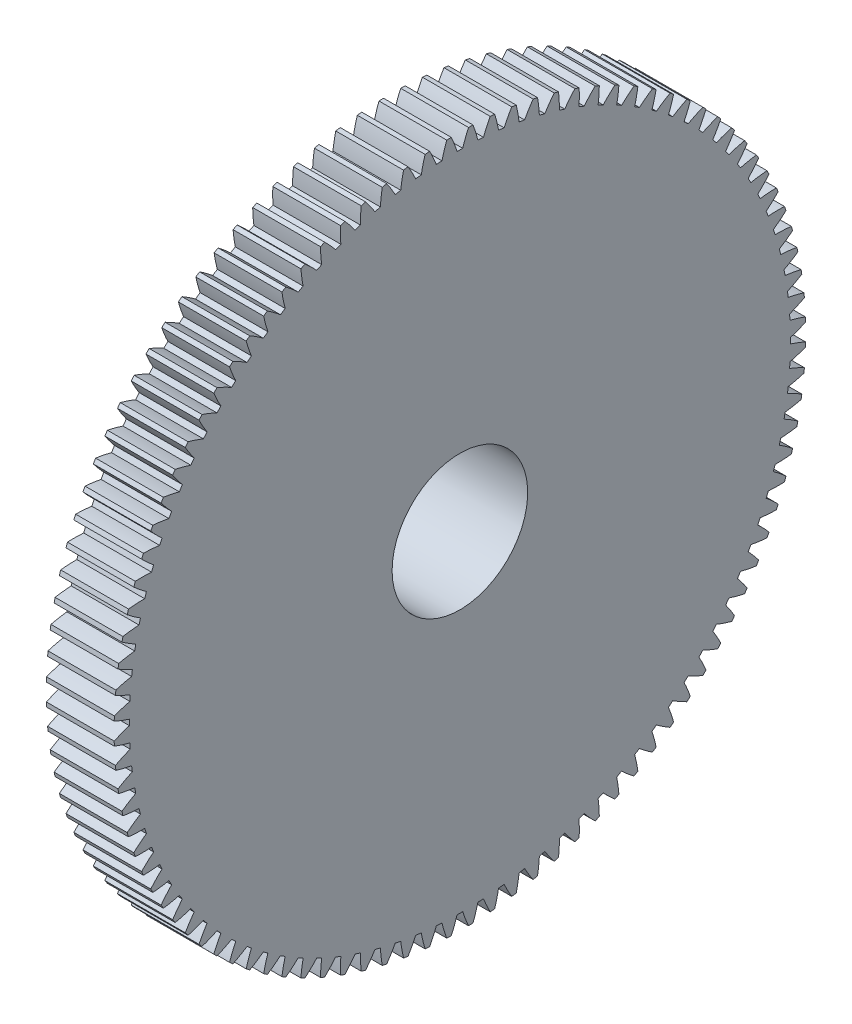
from build123d import *

# Parameters (mm, degrees)
BASPROSKE_W         = 10
BASPROSKE_H         = 51
TOOTHCUT_DEPTH      = 73.814833654
TEETHCUTS_COUNT     = 100
TEETHCUTS_ANGLE     = 356.4
HUBNEAONESKE_R      = 15
HUBNEARONE_DEPTH    = 12.7000508
BORSKE_R            = 10
BORE_DEPTH          = 10.0000508
SKETCH_1_R          = 39.02724458
CUT_EXTRUDE_1_DEPTH = 10


with BuildPart() as part:
    # BasProSke → Base-Revolve (revolve)
    with BuildSketch(Plane(origin=(0, 0, 0), x_dir=(1, 0, 0), z_dir=(0, 1, 0)), mode=Mode.PRIVATE) as base_revolve_sk:
        with Locations((5, 25.5)):
            Rectangle(BASPROSKE_W, BASPROSKE_H)
    revolve(base_revolve_sk.sketch.rotate(Axis((-10, 0, 0), (1, 0, 0)), 180), axis=Axis((-10, 0, 0), (1, 0, 0)))

    # TooCutSke → ToothCut (cut, through all)
    with BuildSketch(Plane(origin=(0, 0, 0), x_dir=(0, 0, -1), z_dir=(1, 0, 0))):
        with BuildLine():
            ThreePointArc((0.414680742, 48.747236238), (0, 48.749), (-0.414680742, 48.747236238))
            ThreePointArc((-0.414680742, 48.747236238), (-0.812805308, 49.891397747), (-1.279472386, 51.009355961))
            ThreePointArc((-1.279472386, 51.009355961), (0, 51.0254), (1.279472386, 51.009355961))
            ThreePointArc((1.279472386, 51.009355961), (0.812805308, 49.891397747), (0.414680742, 48.747236238))
        make_face()
    toothcut = extrude(amount=TOOTHCUT_DEPTH, mode=Mode.SUBTRACT)

    # TeethCuts: ToothCut ×100 about axis
    teethcuts_axis = Axis((-10, 0, 0), (1, 0, 0))
    for i in range(1, TEETHCUTS_COUNT):
        add(toothcut.rotate(teethcuts_axis, i * TEETHCUTS_ANGLE / (TEETHCUTS_COUNT - 1)), mode=Mode.SUBTRACT)

    # HubNeaOneSke → HubNearOne (add)
    with BuildSketch(Plane.ZY):
        with Locations(Location((0, 0, 0), (0, 0, 180))):
            Circle(HUBNEAONESKE_R)
    extrude(amount=HUBNEARONE_DEPTH)

    # BorSke → Bore (cut, symmetric)
    with BuildSketch(Plane(origin=(0, 0, 0), x_dir=(0, 0, -1), z_dir=(1, 0, 0))):
        with Locations(Location((0, 0, 0), (0, 0, 180))):
            Circle(BORSKE_R)
    extrude(amount=BORE_DEPTH, both=True, mode=Mode.SUBTRACT)

    # 草图1 → 切除-拉伸1 (cut)
    with BuildSketch(Plane.ZY.offset(10)):
        Circle(SKETCH_1_R)
    extrude(amount=CUT_EXTRUDE_1_DEPTH, mode=Mode.SUBTRACT)


solid = part.part
